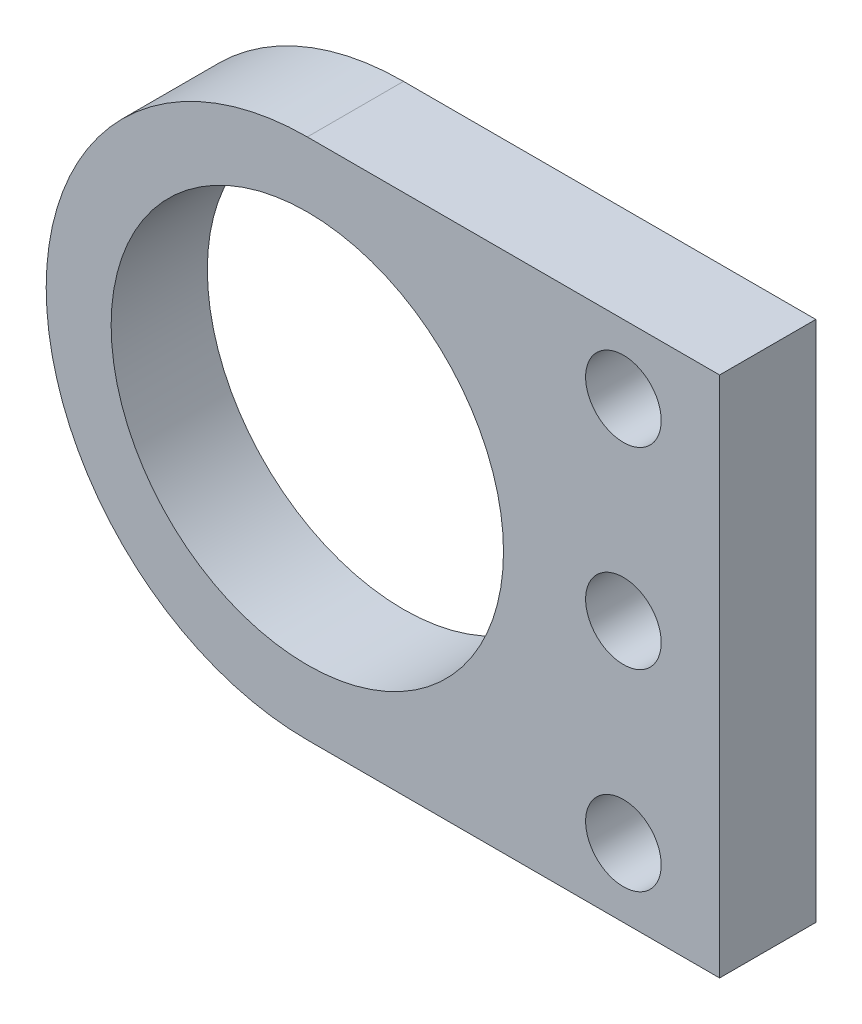
from build123d import *

# Parameters (mm, degrees)
SKETCH1_R           = 14.275
SKETCH1_R_2         = 2.75
BOSS_EXTRUDE1_DEPTH = 7


with BuildPart() as part:
    # Sketch1 → Boss-Extrude1 (new body)
    with BuildSketch(Plane.XY):
        with BuildLine():
            Line((0, -19), (30, -19))
            Line((30, -19), (30, 19))
            Line((30, 19), (0, 19))
            ThreePointArc((0, 19), (-19, 0), (0, -19))
        make_face()
        Circle(SKETCH1_R, mode=Mode.SUBTRACT)
        with Locations((23, 14)):
            Circle(SKETCH1_R_2, mode=Mode.SUBTRACT)
        with Locations((23, 0)):
            Circle(SKETCH1_R_2, mode=Mode.SUBTRACT)
        with Locations((23, -14)):
            Circle(SKETCH1_R_2, mode=Mode.SUBTRACT)
    extrude(amount=BOSS_EXTRUDE1_DEPTH)


solid = part.part
